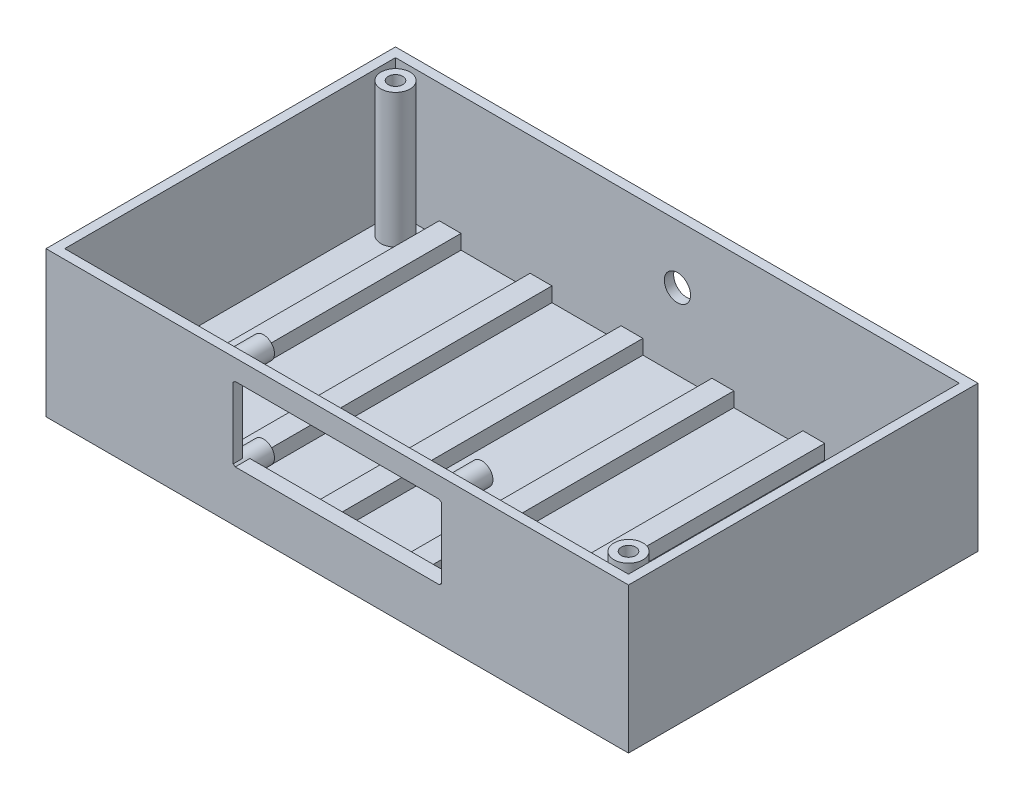
from build123d import *

# Parameters (mm, degrees)
CROQUIS1_W                   = 200
CROQUIS1_H                   = 120
SALIENTE_EXTRUIR1_DEPTH      = 50
CROQUIS2_W                   = 193.6
CROQUIS2_H                   = 113.6
CORTAR_EXTRUIR1_DEPTH        = 46
CROQUIS3_W                   = 71.5
CROQUIS3_H                   = 25.4
CORTAR_EXTRUIR2_DEPTH        = 3.5
CROQUIS4_R                   = 3.75
SALIENTE_EXTRUIR2_DEPTH      = 12.2
CROQUIS5_W                   = 71.5
CROQUIS5_H                   = 4
SALIENTE_EXTRUIR3_DEPTH      = 5
SALIENTE_EXTRUIR4_DEPTH      = 5
SALIENTE_EXTRUIR4_DEPTH_BACK = 5
CROQUIS6_W                   = 7.5
CROQUIS6_H                   = 113.6
CROQUIS7_R                   = 4.5
CORTAR_EXTRUIR3_DEPTH        = 3.3
CROQUIS6_5_R                 = 5
SALIENTE_EXTRUIR5_DEPTH      = 46
SALIENTE_EXTRUIR6_DEPTH      = 5
SALIENTE_EXTRUIR6_DEPTH_BACK = 5
CROQUIS6_6_R                 = 5
CROQUIS8_R                   = 2.5
CORTAR_EXTRUIR4_DEPTH        = 20
CROQUIS9_R                   = 2.5
CORTAR_EXTRUIR5_DEPTH        = 124.616341962


with BuildPart() as part:
    # Croquis1 → Saliente-Extruir1 (new body)
    with BuildSketch(Plane(origin=(0, 0, 0), x_dir=(1, 0, 0), z_dir=(0, 1, 0))):
        Rectangle(CROQUIS1_W, CROQUIS1_H)
    extrude(amount=SALIENTE_EXTRUIR1_DEPTH)

    # Croquis2 → Cortar-Extruir1 (cut)
    with BuildSketch(Plane(origin=(0, 50, 0), x_dir=(1, 0, 0), z_dir=(0, 1, 0))):
        Rectangle(CROQUIS2_W, CROQUIS2_H)
    extrude(amount=-CORTAR_EXTRUIR1_DEPTH, mode=Mode.SUBTRACT)

    # Croquis3 → Cortar-Extruir2 (cut)
    with BuildSketch(Plane.XY.offset(60)):
        with Locations((0, 30.3)):
            Rectangle(CROQUIS3_W, CROQUIS3_H)
    extrude(amount=-CORTAR_EXTRUIR2_DEPTH, mode=Mode.SUBTRACT)

    # Croquis4 → Saliente-Extruir2 (add)
    with BuildSketch(Plane.XY.offset(60)):
        with Locations((-37.5, 45.8)):
            Circle(CROQUIS4_R)
        with Locations((37.5, 45.8)):
            Circle(CROQUIS4_R)
        with Locations((37.5, 14.8)):
            Circle(CROQUIS4_R)
        with Locations((-37.5, 14.8)):
            Circle(CROQUIS4_R)
    extrude(amount=-SALIENTE_EXTRUIR2_DEPTH)

    # Croquis5 → Saliente-Extruir3 (add)
    with BuildSketch(Plane.XY.offset(60)):
        with Locations((0, 15.6)):
            Rectangle(CROQUIS5_W, CROQUIS5_H)
        with Locations((0, 45)):
            Rectangle(CROQUIS5_W, CROQUIS5_H)
    extrude(amount=-SALIENTE_EXTRUIR3_DEPTH)

    # Croquis6 → Saliente-Extruir4 (add, two sides: drawn at the far end of the back side and taken through both)
    with BuildSketch(Plane(origin=(0, 4, 0), x_dir=(1, 0, 0), z_dir=(0, 1, 0)).offset(-SALIENTE_EXTRUIR4_DEPTH_BACK)):
        with Locations((-78.05, 0)):
            Rectangle(CROQUIS6_W, CROQUIS6_H)
        with Locations((-46.83, 0)):
            Rectangle(CROQUIS6_W, CROQUIS6_H)
        with Locations((-15.61, 0)):
            Rectangle(CROQUIS6_W, CROQUIS6_H)
        with Locations((15.61, 0)):
            Rectangle(CROQUIS6_W, CROQUIS6_H)
        with Locations((46.83, 0)):
            Rectangle(CROQUIS6_W, CROQUIS6_H)
        with Locations((78.05, 0)):
            Rectangle(CROQUIS6_W, CROQUIS6_H)
    extrude(amount=SALIENTE_EXTRUIR4_DEPTH + SALIENTE_EXTRUIR4_DEPTH_BACK)

    # Croquis7 → Cortar-Extruir3 (cut)
    with BuildSketch(Plane(origin=(0, 0, -60), x_dir=(-1, 0, 0), z_dir=(0, 0, -1))):
        with Locations((0, 30)):
            Circle(CROQUIS7_R)
    extrude(amount=-CORTAR_EXTRUIR3_DEPTH, mode=Mode.SUBTRACT)

    # Croquis6_5 → Saliente-Extruir5 (add)
    with BuildSketch(Plane(origin=(0, 4, 0), x_dir=(1, 0, 0), z_dir=(0, 1, 0))):
        with Locations((-90, 50)):
            Circle(CROQUIS6_5_R)
        with Locations((90, -50)):
            Circle(CROQUIS6_5_R)
    extrude(amount=SALIENTE_EXTRUIR5_DEPTH)

    # Croquis6_6 → Saliente-Extruir6 (add, two sides: drawn at the far end of the back side and taken through both)
    with BuildSketch(Plane(origin=(0, 4, 0), x_dir=(1, 0, 0), z_dir=(0, 1, 0)).offset(-SALIENTE_EXTRUIR6_DEPTH_BACK)):
        with Locations((90, 50)):
            Circle(CROQUIS6_6_R)
        with Locations((-90, -50)):
            Circle(CROQUIS6_6_R)
    extrude(amount=SALIENTE_EXTRUIR6_DEPTH + SALIENTE_EXTRUIR6_DEPTH_BACK)

    # Croquis8 → Cortar-Extruir4 (cut)
    with BuildSketch(Plane(origin=(0, 50, 0), x_dir=(1, 0, 0), z_dir=(0, 1, 0))):
        with Locations((-90, 50)):
            Circle(CROQUIS8_R)
        with Locations((90, -50)):
            Circle(CROQUIS8_R)
    extrude(amount=-CORTAR_EXTRUIR4_DEPTH, mode=Mode.SUBTRACT)

    # Croquis9 → Cortar-Extruir5 (cut, through all)
    with BuildSketch(Plane(origin=(0, 9, 0), x_dir=(1, 0, 0), z_dir=(0, 1, 0))):
        with Locations((-90, -50)):
            Circle(CROQUIS9_R)
        with Locations((90, 50)):
            Circle(CROQUIS9_R)
    extrude(amount=-CORTAR_EXTRUIR5_DEPTH, mode=Mode.SUBTRACT)


solid = part.part
